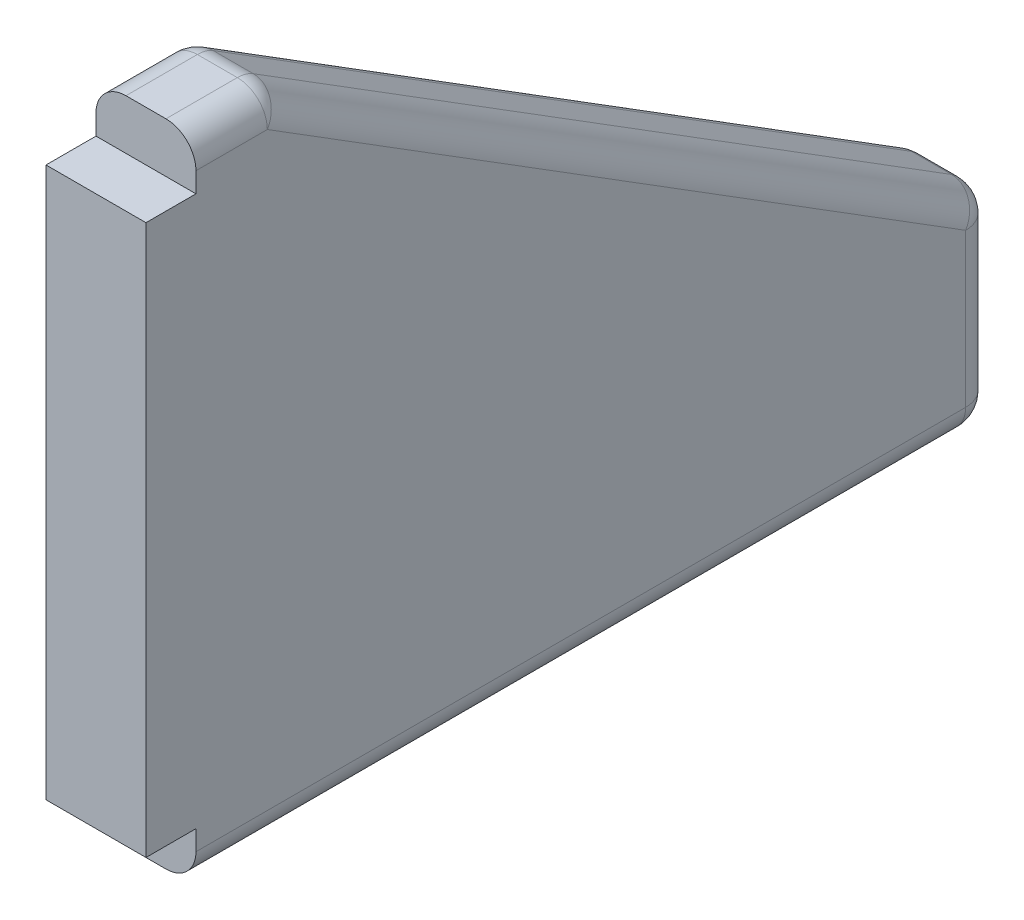
from build123d import *

# Parameters (mm, degrees)
BOSS_EXTRUDE5_DEPTH = 10
FILLET1_R           = 3


with BuildPart() as part:
    # Sketch7 → Boss-Extrude5 (new body)
    with BuildSketch(Plane(origin=(0, 0, 0), x_dir=(0, 0, -1), z_dir=(1, 0, 0))):
        Polygon((0, 0), (0, 5), (-5, 5), (-5, 60), (0, 60), (0, 65), (8, 65), (80, 20), (80, 0), align=None)
    extrude(amount=BOSS_EXTRUDE5_DEPTH)

    # Fillet1
    fillet1_edges = [part.edges().sort_by_distance(p)[0] for p in [
        (0, 65, -4),
        (0, 42.5, -44),
        (0, 10, -80),
        (0, 0, -40),
        (10, 42.5, -44),
        (5, 65, -8),
        (5, 20, -80),
        (5, 0, -80),
        (10, 65, -4),
        (10, 0, -40),
        (10, 10, -80),
    ]]
    fillet(fillet1_edges, radius=FILLET1_R)


solid = part.part
